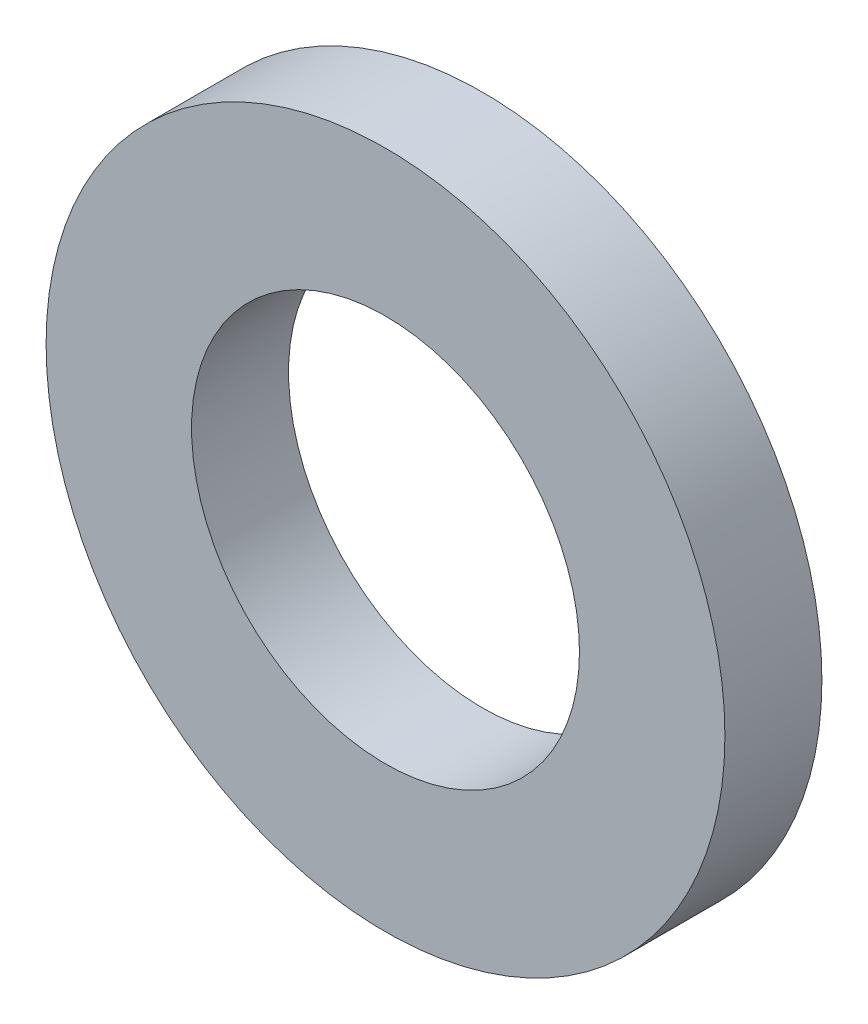
from build123d import *

# Parameters (mm, degrees)
ESQUISSE1_R        = 3.5
ESQUISSE1_R_2      = 2
BOSS_EXTRU_1_DEPTH = 1


with BuildPart() as part:
    # Esquisse1 → Boss.-Extru.1 (new body)
    with BuildSketch(Plane.XY):
        Circle(ESQUISSE1_R)
        Circle(ESQUISSE1_R_2, mode=Mode.SUBTRACT)
    extrude(amount=BOSS_EXTRU_1_DEPTH)


solid = part.part
